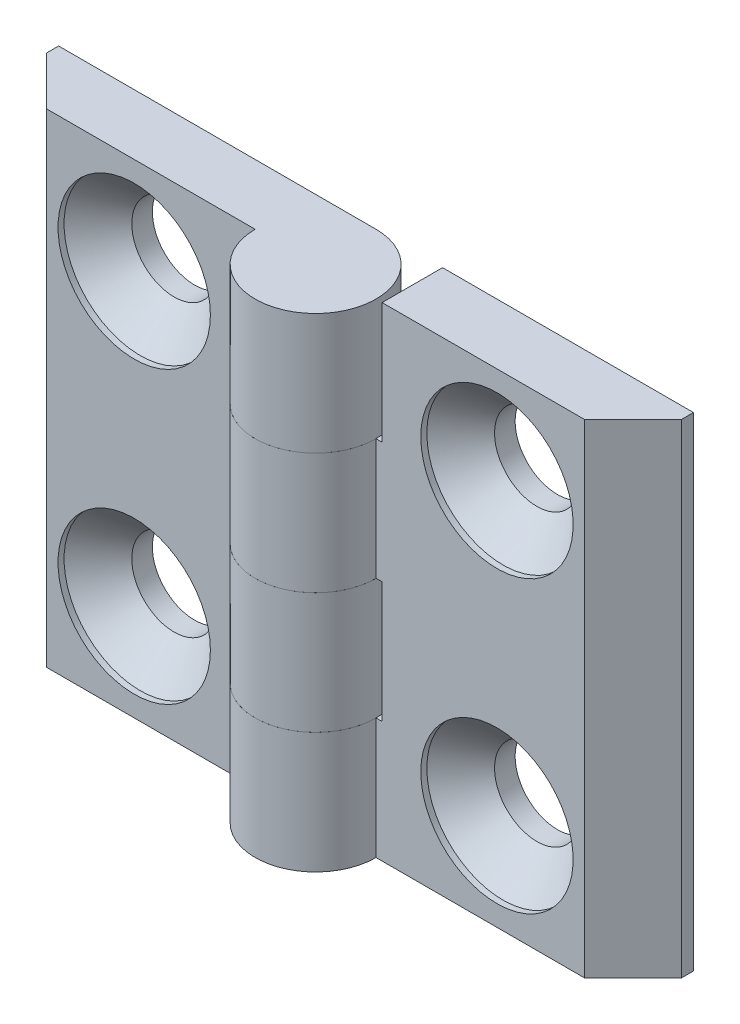
from build123d import *

# Parameters (mm, degrees)
EXTRUDE_1_DEPTH            = 20
SKETCH_3_W                 = 10.5
SKETCH_3_H                 = 10
CUT_EXTRUDE_1_DEPTH        = 6
CUT_EXTRUDE_1_DEPTH_BACK   = 6
HOLE_WIZARD_M61_AT_2_COUNT = 2
HOLE_WIZARD_M61_AT_2_PITCH = 24
PATTERN_CIRCULAR_1_COUNT   = 2


with BuildPart() as part:
    # Эскиз1 → Бобышка-Вытянуть1 (new body, symmetric)
    with BuildSketch(Plane(origin=(0, 0, 0), x_dir=(1, 0, 0), z_dir=(0, 1, 0))):
        with BuildLine():
            Line((0, 5), (-26.25, 5))
            Line((-26.25, 5), (-26.25, 4))
            Line((-26.25, 4), (-22.25, 0))
            Line((-22.25, 0), (-5, 0))
            ThreePointArc((-5, 0), (3.535533906, -3.535533906), (0, 5))
        make_face()
    extrude(amount=EXTRUDE_1_DEPTH, both=True)

    # Эскиз3 → Вырез-Вытянуть1 (cut, two sides)
    with BuildSketch(Plane.XY) as cut_extrude_1_sk:
        with Locations((-0.25, 5)):
            Rectangle(SKETCH_3_W, SKETCH_3_H)
        with Locations((-0.25, -15)):
            Rectangle(SKETCH_3_W, SKETCH_3_H)
    extrude(amount=CUT_EXTRUDE_1_DEPTH, mode=Mode.SUBTRACT)
    extrude(cut_extrude_1_sk.sketch, amount=-CUT_EXTRUDE_1_DEPTH_BACK, mode=Mode.SUBTRACT)

    # Эскиз6 → Зенковка для винта с полупотайной головкой M61 (revolve, cut)
    with BuildSketch(Plane(origin=(-15, 12, 0), x_dir=(0, -1, 0), z_dir=(1, 0, 0))):
        Polygon((0, 0), (0, 5), (3.5, 5), (3.5, 3.3), (6.3, 0.5), (6.3, 0), align=None)
    hole_wizard_m61 = revolve(axis=Axis((-15, 12, 6.35), (0, 0, -1)), mode=Mode.SUBTRACT)

    # Зенковка для винта с полупотайной головкой M61 at 2: Зенковка для винта с полупотайной головкой M61 ×2
    with Locations(*[(0, -i * HOLE_WIZARD_M61_AT_2_PITCH, 0) for i in range(1, HOLE_WIZARD_M61_AT_2_COUNT)]):
        add(hole_wizard_m61, mode=Mode.SUBTRACT)


with BuildPart() as pattern_circular_1_1:
    # Круговой массив1: pattern copy
    add(part.part.rotate(Axis((0, 0, 0), (0, 0, 1)), 1 * 360 / PATTERN_CIRCULAR_1_COUNT))


solid = Compound([part.part, pattern_circular_1_1.part])
